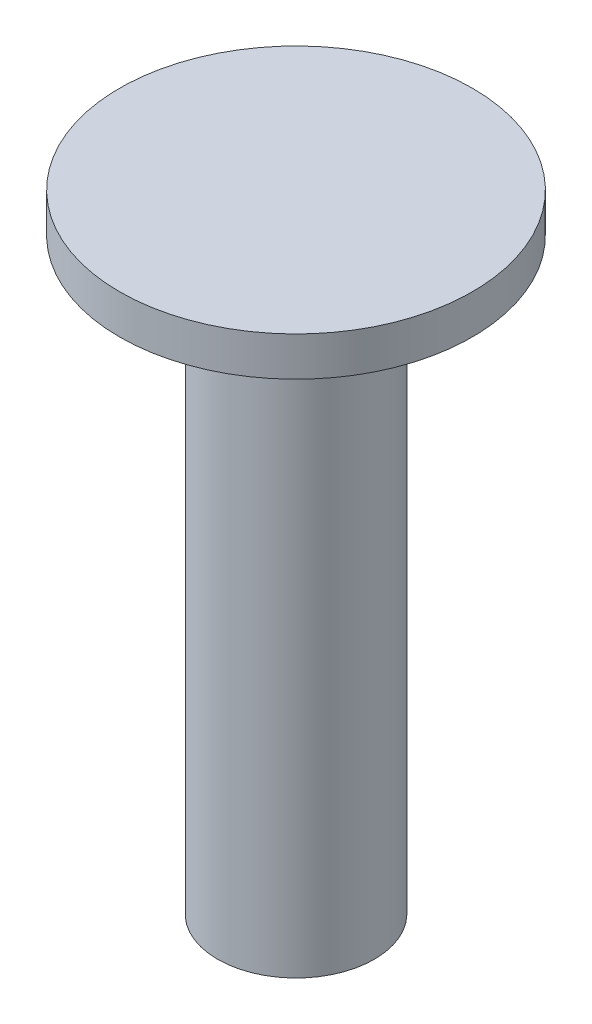
from build123d import *

# Parameters (mm, degrees)
SKETCH1_R           = 4
BOSS_EXTRUDE1_DEPTH = 30
SKETCH2_R           = 9
BOSS_EXTRUDE2_DEPTH = 2


with BuildPart() as part:
    # Sketch1 → Boss-Extrude1 (new body)
    with BuildSketch(Plane(origin=(0, 0, 0), x_dir=(1, 0, 0), z_dir=(0, 1, 0))):
        Circle(SKETCH1_R)
    extrude(amount=BOSS_EXTRUDE1_DEPTH)

    # Sketch2 → Boss-Extrude2 (add)
    with BuildSketch(Plane(origin=(0, 30, 0), x_dir=(1, 0, 0), z_dir=(0, 1, 0))):
        Circle(SKETCH2_R)
    extrude(amount=BOSS_EXTRUDE2_DEPTH)


solid = part.part
